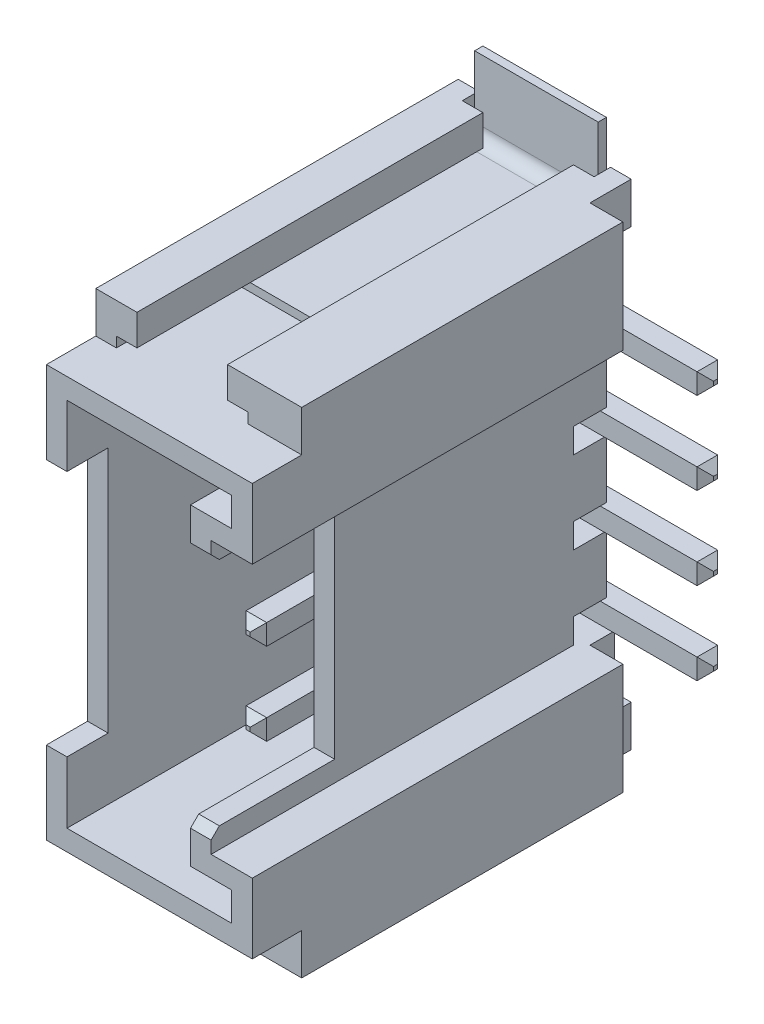
from build123d import *

# Parameters (mm, degrees)
BOSS_EXTRU_1_DEPTH         = 10
ENL_V_MAT_EXTRU_1_DEPTH    = 6.5
ESQUISSE5_W                = 2
ESQUISSE5_H                = 6
ENL_V_MAT_EXTRU_2_DEPTH    = 1.5
ESQUISSE6_W                = 6
ESQUISSE6_H                = 5.6
ENL_V_MAT_EXTRU_3_DEPTH    = 2.5
CHANFREIN1_SIZE            = 0.2
ESQUISSE7_W                = 1.2
ESQUISSE7_H                = 1
ENL_V_MAT_EXTRU_4_DEPTH    = 6
ESQUISSE8_W                = 0.8
ESQUISSE8_H                = 1
ESQUISSE8_W_2              = 3.2
ESQUISSE8_H_2              = 0.4
ENL_V_MAT_EXTRU_5_DEPTH    = 13
EXTRU_MINCE1_START         = 3
EXTRU_MINCE1_DEPTH         = 0.25
CHANFREIN2_SIZE            = 0.2
R_P_TITION_LIN_AIRE1_COUNT = 4
R_P_TITION_LIN_AIRE1_PITCH = 2
EXTRU_MINCE2_START         = 0.1
EXTRU_MINCE2_DEPTH         = 3


with BuildPart() as part:
    # Esquisse1 → Boss.-Extru.1 (new body)
    with BuildSketch(Plane.XY):
        Polygon((0, 3.3), (0, 6), (-1.8, 6), (-1.8, 5.25), (-1.3, 5.25), (-1.3, 5), (-4.5, 5), (-4.5, 5.25), (-4, 5.25), (-4, 6), (-5, 6), (-5, -6), (-4, -6), (-4, -5.25), (-4.5, -5.25), (-4.5, -5), (-1.3, -5), (-1.3, -5.25), (-1.8, -5.25), (-1.8, -6), (0, -6), (0, -3.3), (-1, -3.3), (-1, 3.3), align=None)
    extrude(amount=BOSS_EXTRU_1_DEPTH)

    # Esquisse4 → Enlèv. mat.-Extru.1 (cut)
    with BuildSketch(Plane.XY.offset(10)):
        Polygon((-0.5, 4.5), (-4.5, 4.5), (-4.5, -4.5), (-0.5, -4.5), (-0.5, -3.8), (-1.5, -3.8), (-1.5, 3.8), (-0.5, 3.8), align=None)
    extrude(amount=-ENL_V_MAT_EXTRU_1_DEPTH, mode=Mode.SUBTRACT)

    # Esquisse5 → Enlèv. mat.-Extru.2 (cut, through all)
    with BuildSketch(Plane(origin=(-4.5, 0, 0), x_dir=(0, 0, -1), z_dir=(1, 0, 0))):
        with Locations((-10, 0)):
            Rectangle(ESQUISSE5_W, ESQUISSE5_H)
    extrude(amount=-ENL_V_MAT_EXTRU_2_DEPTH, mode=Mode.SUBTRACT)

    # Esquisse6 → Enlèv. mat.-Extru.3 (cut, through all)
    with BuildSketch(Plane.ZY.offset(1.5)):
        with Locations((10, 0)):
            Rectangle(ESQUISSE6_W, ESQUISSE6_H)
    extrude(amount=-ENL_V_MAT_EXTRU_3_DEPTH, mode=Mode.SUBTRACT)

    # Chanfrein1
    chanfrein1_edges = [part.edges().sort_by_distance(p)[0] for p in [
        (-1.25, 2.8, 10),
        (-1.25, -2.8, 10),
    ]]
    chamfer(chanfrein1_edges, length=CHANFREIN1_SIZE)

    # Esquisse7 → Enlèv. mat.-Extru.4 (cut, through all)
    with BuildSketch(Plane.ZY.offset(5)):
        with Locations((9.4, 5.5)):
            Rectangle(ESQUISSE7_W, ESQUISSE7_H)
        with Locations((9.4, -5.5)):
            Rectangle(ESQUISSE7_W, ESQUISSE7_H)
        Polygon((0, 5), (0.4, 5), (0.4, 3.3), (1.2, 3.3), (1.2, 2.7), (0.4, 2.7), (0.4, 1.3), (1.2, 1.3), (1.2, 0.7), (0.4, 0.7), (0.4, -0.7), (1.2, -0.7), (1.2, -1.3), (0.4, -1.3), (0.4, -2.7), (1.2, -2.7), (1.2, -3.3), (0.4, -3.3), (0.4, -5), (0, -5), align=None)
    extrude(amount=-ENL_V_MAT_EXTRU_4_DEPTH, mode=Mode.SUBTRACT)

    # Esquisse8 → Enlèv. mat.-Extru.5 (cut, through all)
    with BuildSketch(Plane(origin=(0, 6, 0), x_dir=(1, 0, 0), z_dir=(0, 1, 0))):
        with Locations((-0.4, -0.5)):
            Rectangle(ESQUISSE8_W, ESQUISSE8_H)
        with Locations((-2.9, -0.2)):
            Rectangle(ESQUISSE8_W_2, ESQUISSE8_H_2)
    extrude(amount=-ENL_V_MAT_EXTRU_5_DEPTH, mode=Mode.SUBTRACT)


with BuildPart() as body_2:
    # Esquisse9 → Extru.-Mince1 (new body, symmetric)
    with BuildSketch(Plane(origin=(0, 0, 0), x_dir=(1, 0, 0), z_dir=(0, 1, 0)).offset(EXTRU_MINCE1_START)):
        with BuildLine():
            Line((-2.65, -7.2), (-2.65, -0.75))
            ThreePointArc((-2.65, -0.75), (-2.576776695, -0.573223305), (-2.4, -0.5))
            Line((-2.4, -0.5), (1.5, -0.5))
            Line((1.5, -0.5), (1.5, 0))
            Line((1.5, 0), (-2.4, 0))
            ThreePointArc((-2.4, 0), (-2.930330086, -0.219669914), (-3.15, -0.75))
            Line((-3.15, -0.75), (-3.15, -7.2))
            Line((-3.15, -7.2), (-2.65, -7.2))
        make_face()
    extrude(amount=EXTRU_MINCE1_DEPTH, both=True)

    # Chanfrein2
    chanfrein2_edges = [body_2.edges().sort_by_distance(p)[0] for p in [
        (-2.65, 3, 7.2),
        (-3.15, 3, 7.2),
        (1.5, 3, 0),
        (1.5, 3, 0.5),
        (-2.9, 3.25, 7.2),
        (1.5, 3.25, 0.25),
        (-2.9, 2.75, 7.2),
        (1.5, 2.75, 0.25),
    ]]
    chamfer(chanfrein2_edges, length=CHANFREIN2_SIZE)


with BuildPart() as r_p_tition_lin_aire1_1:
    # Répétition linéaire1: pattern copy
    add(body_2.part.moved(Location(Vector(0, -1, 0) * (1 * R_P_TITION_LIN_AIRE1_PITCH))))


with BuildPart() as r_p_tition_lin_aire1_2:
    # Répétition linéaire1: pattern copy
    add(body_2.part.moved(Location(Vector(0, -1, 0) * (2 * R_P_TITION_LIN_AIRE1_PITCH))))


with BuildPart() as r_p_tition_lin_aire1_3:
    # Répétition linéaire1: pattern copy
    add(body_2.part.moved(Location(Vector(0, -1, 0) * (3 * R_P_TITION_LIN_AIRE1_PITCH))))


with BuildPart() as body_6:
    # Esquisse10 → Extru.-Mince2 (new body)
    with BuildSketch(Plane(origin=(-4.5, 0, 0), x_dir=(0, 0, -1), z_dir=(1, 0, 0)).offset(EXTRU_MINCE2_START)):
        with BuildLine():
            Line((-6, 5), (-0.5, 5))
            ThreePointArc((-0.5, 5), (-0.146446609, 5.146446609), (0, 5.5))
            Line((0, 5.5), (0, 7))
            Line((0, 7), (-0.2, 7))
            Line((-0.2, 7), (-0.2, 5.5))
            ThreePointArc((-0.2, 5.5), (-0.287867966, 5.287867966), (-0.5, 5.2))
            Line((-0.5, 5.2), (-6, 5.2))
            Line((-6, 5.2), (-6, 5))
        make_face()
    extrude(amount=EXTRU_MINCE2_DEPTH)


with BuildPart() as body_7:
    # Symétrie3: mirrored copy
    add(body_6.part.mirror(Plane.ZX))


solid = Compound([part.part, body_2.part, r_p_tition_lin_aire1_1.part, r_p_tition_lin_aire1_2.part, r_p_tition_lin_aire1_3.part, body_6.part, body_7.part])
